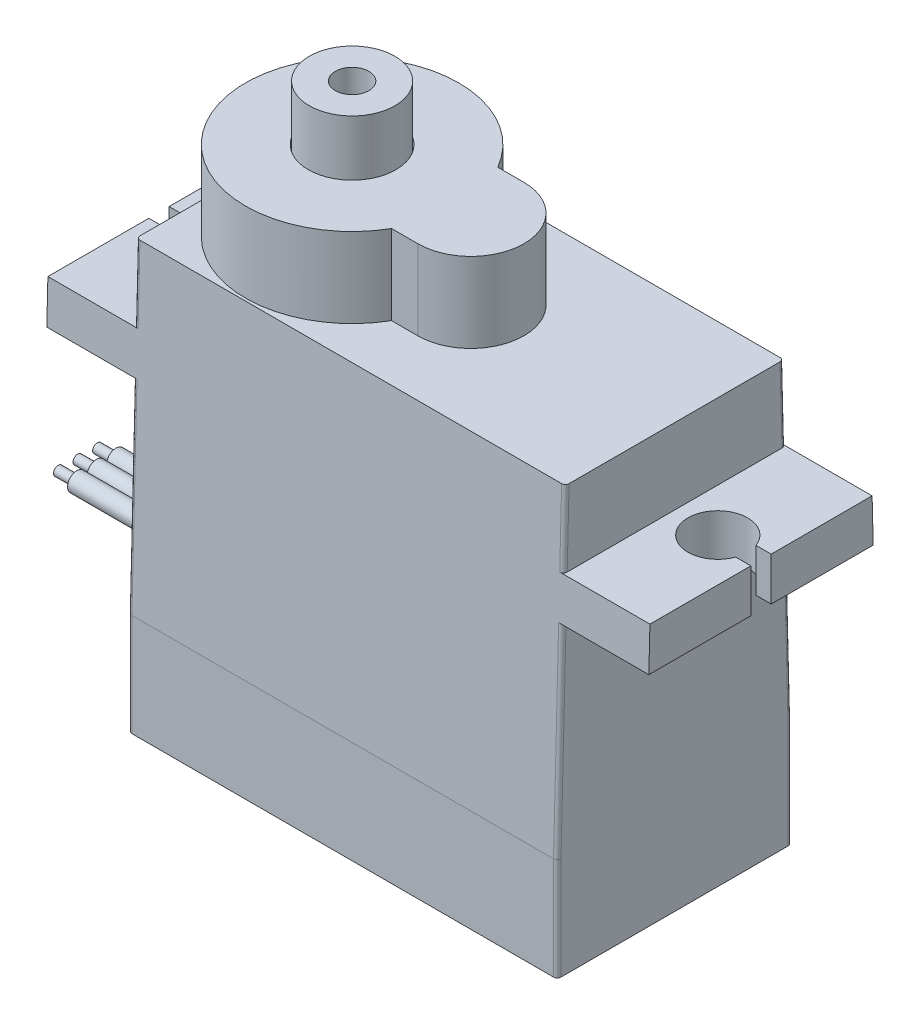
from build123d import *

# Parameters (mm, degrees)
BOSS_EXTRUDE1_DEPTH      = 6.295
BOSS_EXTRUDE2_DEPTH      = 4.28
CUT_EXTRUDE4_DEPTH       = 37.749948639
SKETCH4_R                = 0.975
SKETCH4_W                = 1.511544683
SKETCH4_H                = 1.09
CUT_EXTRUDE1_DEPTH       = 27.991002668
SKETCH5_R                = 1
SKETCH5_R_2              = 0.975
CUT_EXTRUDE2_DEPTH       = 1
SKETCH6_R                = 0.5
BOSS_EXTRUDE4_DEPTH      = 8
SKETCH7_R                = 0.25
BOSS_EXTRUDE5_DEPTH      = 1
FILLET1_R                = 0.3
FILLET3_R                = 0.2
BOSS_EXTRUDE6_DEPTH      = 2.95
BOSS_EXTRUDE6_DEPTH_BACK = 1
SKETCH12_R               = 2.3
SKETCH12_R_2             = 0.9
SKETCH13_R               = 2.35
CUT_EXTRUDE5_DEPTH       = 5
SKETCH15_R               = 1.6
CUT_EXTRUDE6_DEPTH       = 10
SKETCH16_R               = 1.6
CUT_EXTRUDE7_DEPTH       = 10


with BuildPart() as part:
    # Sketch1 → Boss-Extrude1 (new, symmetric)
    with BuildSketch(Plane.XY):
        Polygon((-7.13, 6.38), (15.9, 6.38), (15.9, 2.32), (20.54, 2.32), (20.54, 0), (15.9, 0), (15.9, -16.34), (-7.13, -16.34), (-7.13, 0), (-11.77, 0), (-11.77, 2.32), (-7.13, 2.32), align=None)
    extrude(amount=BOSS_EXTRUDE1_DEPTH, both=True)

    # Sketch2 → Boss-Extrude2 (add)
    with BuildSketch(Plane(origin=(0, 6.38, 0), x_dir=(1, 0, 0), z_dir=(0, 1, 0))):
        with BuildLine():
            Line((3.560191336, -2.85), (4.97, -2.85))
            ThreePointArc((4.97, -2.85), (7.82, 0), (4.97, 2.85))
            Line((4.97, 2.85), (3.560191336, 2.85))
            ThreePointArc((3.560191336, 2.85), (-7.13, 0), (3.560191336, -2.85))
        make_face()
    extrude(amount=BOSS_EXTRUDE2_DEPTH)

    # Sketch11 → Cut-Extrude4 (cut, through all)
    with BuildSketch(Plane.ZY.offset(11.77)):
        Polygon((-5.86, 6.38), (-6.295, -10.84), (-6.295, 6.38), align=None)
    cut_extrude4 = extrude(amount=-CUT_EXTRUDE4_DEPTH, mode=Mode.SUBTRACT)

    # Mirror1: Cut-Extrude4 across plane
    add(cut_extrude4.mirror(Plane.XY), mode=Mode.SUBTRACT)

    # Sketch4 → Cut-Extrude1 (cut, through all)
    with BuildSketch(Plane(origin=(0, 0, 0), x_dir=(1, 0, 0), z_dir=(0, 1, 0))):
        with Locations((-9.45, 0)):
            Circle(SKETCH4_R)
        with Locations((-11.014227659, 0)):
            Rectangle(SKETCH4_W, SKETCH4_H)
    cut_extrude1 = extrude(amount=CUT_EXTRUDE1_DEPTH, mode=Mode.SUBTRACT)

    # Mirror2: Cut-Extrude1 across plane
    add(cut_extrude1.mirror(Plane(origin=(4.385, -10.84, 6.295), x_dir=(0, 0, 1), z_dir=(-1, 0, 0))), mode=Mode.SUBTRACT)

    # Sketch5 → Cut-Extrude2 (cut)
    # profile 1 of 4: a face of its own
    with BuildSketch(Plane.XZ.offset(16.34)):
        with Locations((-5.49, 4.35)):
            Circle(SKETCH5_R)
        with Locations((-5.49, 4.35)):
            Circle(SKETCH5_R_2, mode=Mode.SUBTRACT)
    # profile 2 of 4: a face of its own
    with BuildSketch(Plane.XZ.offset(16.34)):
        with Locations((-5.49, -4.35)):
            Circle(SKETCH5_R)
        with Locations((-5.49, -4.35)):
            Circle(SKETCH5_R_2, mode=Mode.SUBTRACT)
    # profile 3 of 4: a face of its own
    with BuildSketch(Plane.XZ.offset(16.34)):
        with Locations((14.26, -4.35)):
            Circle(SKETCH5_R)
        with Locations((14.26, -4.35)):
            Circle(SKETCH5_R_2, mode=Mode.SUBTRACT)
    # profile 4 of 4: a face of its own
    with BuildSketch(Plane.XZ.offset(16.34)):
        with Locations((14.26, 4.35)):
            Circle(SKETCH5_R)
        with Locations((14.26, 4.35)):
            Circle(SKETCH5_R_2, mode=Mode.SUBTRACT)
    extrude(amount=-CUT_EXTRUDE2_DEPTH, mode=Mode.SUBTRACT)

    # Sketch6 → Boss-Extrude4 (add)
    with BuildSketch(Plane.ZY.offset(7.13)):
        with Locations((0, -11.34)):
            Circle(SKETCH6_R)
        with Locations((1.05, -11.34)):
            Circle(SKETCH6_R)
        with Locations((-1.05, -11.34)):
            Circle(SKETCH6_R)
    extrude(amount=BOSS_EXTRUDE4_DEPTH)

    # Sketch7 → Boss-Extrude5 (add)
    with BuildSketch(Plane.ZY.offset(15.13)):
        with Locations((0, -11.34)):
            Circle(SKETCH7_R)
        with Locations((1.05, -11.34)):
            Circle(SKETCH7_R)
        with Locations((-1.05, -11.34)):
            Circle(SKETCH7_R)
    extrude(amount=BOSS_EXTRUDE5_DEPTH)

    # Fillet1
    fillet1_edges = [part.edges().sort_by_distance(p)[0] for p in [
        (13.285, -16.34, -4.35),
        (13.285, -16.34, 4.35),
        (-6.465, -16.34, -4.35),
        (-6.465, -16.34, 4.35),
    ]]
    fillet(fillet1_edges, radius=FILLET1_R)

    # Fillet3
    fillet3_edges = [part.edges().sort_by_distance(p)[0] for p in [
        (15.9, -13.59, -6.295),
        (15.9, -13.59, 6.295),
        (-7.13, -13.59, -6.295),
        (-7.13, -13.59, 6.295),
        (-7.13, -5.42, 6.158083624),
        (-7.13, -5.42, -6.158083624),
        (15.9, -5.42, 6.158083624),
        (15.9, -5.42, -6.158083624),
        (15.9, 4.35, -5.911280488),
        (15.9, 4.35, 5.911280488),
        (-7.13, 4.35, -5.911280488),
        (-7.13, 4.35, 5.911280488),
    ]]
    fillet(fillet3_edges, radius=FILLET3_R)

    # Sketch13 → Cut-Extrude5 (cut)
    with BuildSketch(Plane(origin=(0, 13.61, 0), x_dir=(1, 0, 0), z_dir=(0, 1, 0))):
        with Locations((-1.405, 0)):
            Circle(SKETCH13_R)
    extrude(amount=-CUT_EXTRUDE5_DEPTH, mode=Mode.SUBTRACT)

    # Sketch15 → Cut-Extrude6 (cut)
    with BuildSketch(Plane(origin=(0, 2.32, 0), x_dir=(1, 0, 0), z_dir=(0, 1, 0))):
        with Locations((18.22, 0)):
            Circle(SKETCH15_R)
    extrude(amount=-CUT_EXTRUDE6_DEPTH, mode=Mode.SUBTRACT)

    # Sketch16 → Cut-Extrude7 (cut)
    with BuildSketch(Plane(origin=(0, 2.32, 0), x_dir=(1, 0, 0), z_dir=(0, 1, 0))):
        with Locations((-9.45, 0)):
            Circle(SKETCH16_R)
    extrude(amount=-CUT_EXTRUDE7_DEPTH, mode=Mode.SUBTRACT)


with BuildPart() as body_2:
    # Sketch12 → Boss-Extrude6 (new, two sides: drawn at the far end of the back side and taken through both)
    with BuildSketch(Plane(origin=(0, 10.66, 0), x_dir=(1, 0, 0), z_dir=(0, 1, 0)).offset(-BOSS_EXTRUDE6_DEPTH_BACK)):
        with Locations((-1.405, 0)):
            Circle(SKETCH12_R)
        with Locations((-1.405, 0)):
            Circle(SKETCH12_R_2, mode=Mode.SUBTRACT)
    extrude(amount=BOSS_EXTRUDE6_DEPTH + BOSS_EXTRUDE6_DEPTH_BACK)


solid = Compound([part.part, body_2.part])
